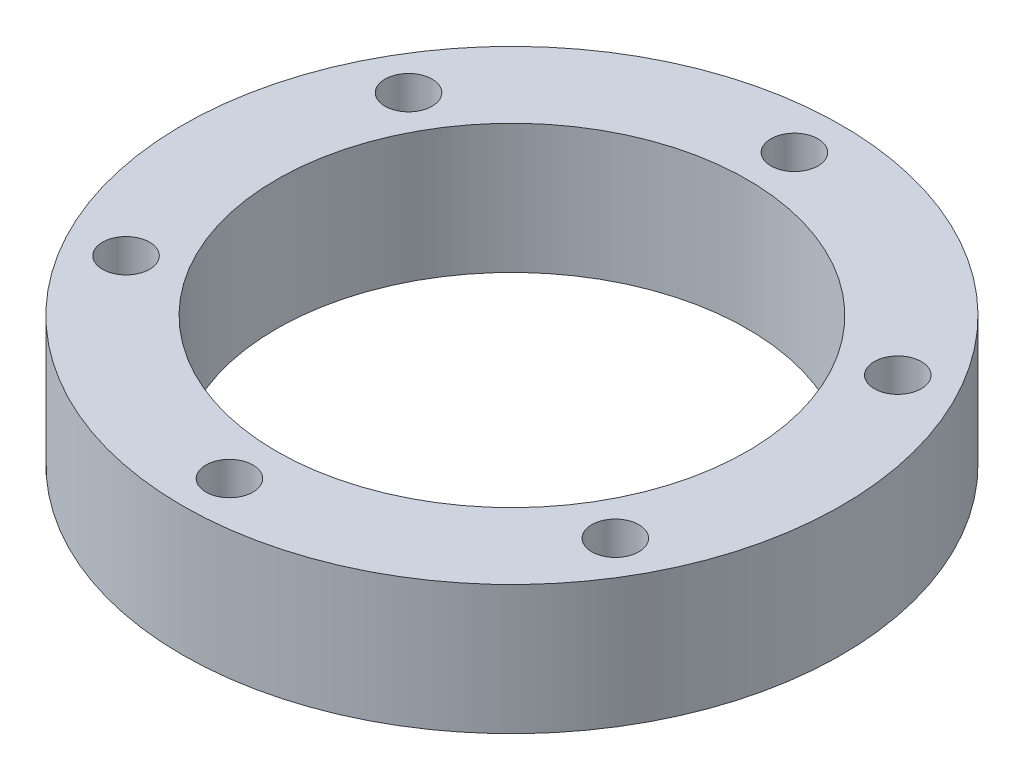
from build123d import *

# Parameters (mm, degrees)
SKETCH1_R           = 17.5
BOSS_EXTRUDE1_DEPTH = 6.86
SKETCH2_R           = 12.5
CUT_EXTRUDE1_DEPTH  = 6.86
SKETCH3_R           = 1.25
CUT_EXTRUDE2_DEPTH  = 6.86
CIRPATTERN2_COUNT   = 6


with BuildPart() as part:
    # Sketch1 → Boss-Extrude1 (new body)
    with BuildSketch(Plane(origin=(0, 0, 0), x_dir=(1, 0, 0), z_dir=(0, 1, 0))):
        Circle(SKETCH1_R)
    extrude(amount=BOSS_EXTRUDE1_DEPTH)

    # Sketch2 → Cut-Extrude1 (cut)
    with BuildSketch(Plane(origin=(0, 6.86, 0), x_dir=(1, 0, 0), z_dir=(0, 1, 0))):
        Circle(SKETCH2_R)
    extrude(amount=-CUT_EXTRUDE1_DEPTH, mode=Mode.SUBTRACT)

    # Sketch3 → Cut-Extrude2 (cut)
    with BuildSketch(Plane(origin=(0, 6.86, 0), x_dir=(1, 0, 0), z_dir=(0, 1, 0))):
        with Locations((0, 15)):
            Circle(SKETCH3_R)
    cut_extrude2 = extrude(amount=-CUT_EXTRUDE2_DEPTH, mode=Mode.SUBTRACT)

    # CirPattern2: Cut-Extrude2 ×6 about axis
    cirpattern2_axis = Axis((0, 0, 0), (0, 1, 0))
    for i in range(1, CIRPATTERN2_COUNT):
        add(cut_extrude2.rotate(cirpattern2_axis, i * 360 / CIRPATTERN2_COUNT), mode=Mode.SUBTRACT)


solid = part.part
